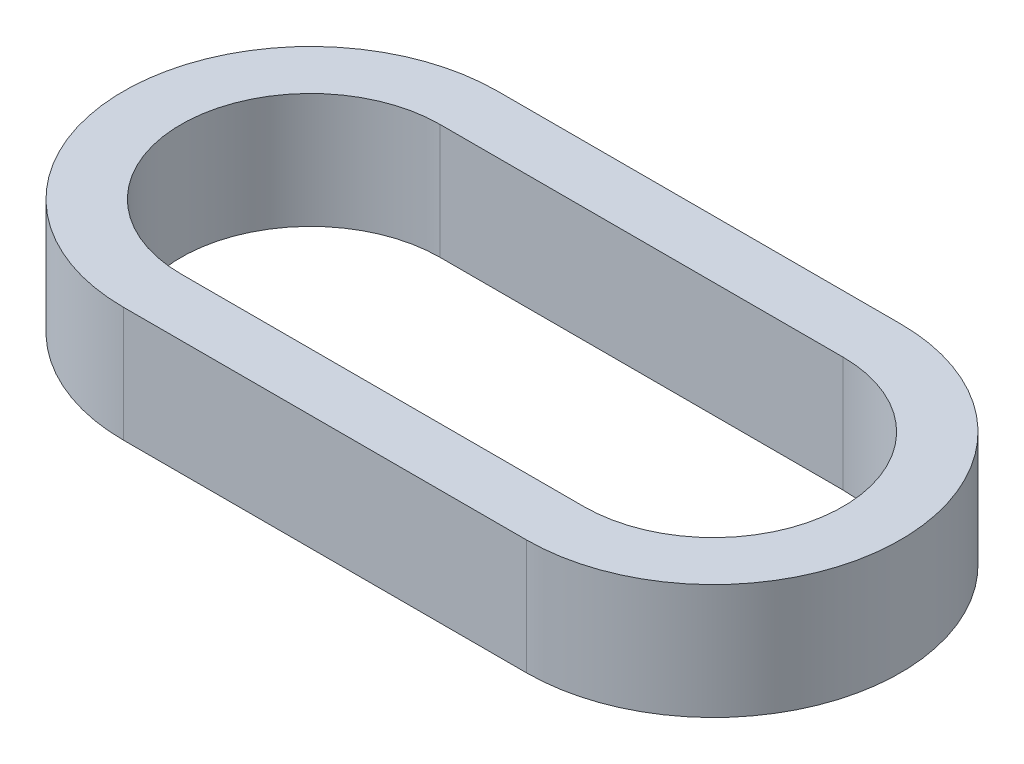
from build123d import *

# Parameters (mm, degrees)
VYSUNOUT_TENKOST_NN_1_DEPTH = 2


with BuildPart() as part:
    # Skica1 → Vysunout tenkostěnný1 (new body)
    with BuildSketch(Plane(origin=(0, 0, 0), x_dir=(1, 0, 0), z_dir=(0, 1, 0))):
        with BuildLine():
            Line((3.5, -3.25), (-3.5, -3.25))
            ThreePointArc((-3.5, -3.25), (-6.75, 0), (-3.5, 3.25))
            Line((-3.5, 3.25), (3.5, 3.25))
            ThreePointArc((3.5, 3.25), (6.75, 0), (3.5, -3.25))
        make_face()
        with BuildLine():
            Line((3.5, -2.25), (-3.5, -2.25))
            ThreePointArc((-3.5, -2.25), (-5.75, 0), (-3.5, 2.25))
            Line((-3.5, 2.25), (3.5, 2.25))
            ThreePointArc((3.5, 2.25), (5.75, 0), (3.5, -2.25))
        make_face(mode=Mode.SUBTRACT)
    extrude(amount=VYSUNOUT_TENKOST_NN_1_DEPTH)


solid = part.part
